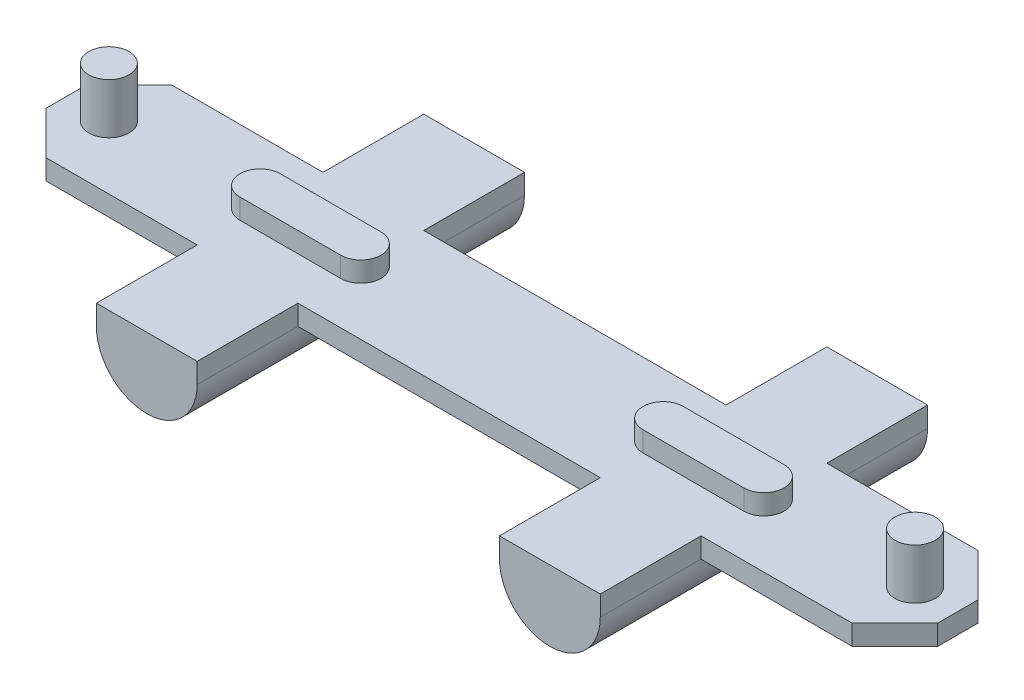
from build123d import *

# Parameters (mm, degrees)
SALIENTE_EXTRUIR1_DEPTH = 2
SALIENTE_EXTRUIR3_DEPTH = 2
CROQUIS3_R              = 2
SALIENTE_EXTRUIR4_DEPTH = 5
SALIENTE_EXTRUIR5_DEPTH = 32.48


with BuildPart() as part:
    # Croquis1 → Saliente-Extruir1 (new body)
    with BuildSketch(Plane(origin=(0, 0, 0), x_dir=(1, 0, 0), z_dir=(0, 1, 0))):
        Polygon((0, 0), (0, 4), (4.242640687, 8.242640687), (19.242640687, 8.242640687), (19.242640687, 18.242640687), (29.242640687, 18.242640687), (29.242640687, 8.242640687), (59.242640687, 8.242640687), (59.242640687, 18.242640687), (69.242640687, 18.242640687), (69.242640687, 8.242640687), (84.242640687, 8.242640687), (88.485281374, 4), (88.485281374, 0), (84.242640687, -4.242640687), (69.242640687, -4.242640687), (69.242640687, -14.242640687), (59.242640687, -14.242640687), (59.242640687, -4.242640687), (29.242640687, -4.242640687), (29.242640687, -14.242640687), (19.242640687, -14.242640687), (19.242640687, -4.242640687), (4.242640687, -4.242640687), align=None)
    extrude(amount=SALIENTE_EXTRUIR1_DEPTH)

    # Croquis2 → Saliente-Extruir3 (add)
    with BuildSketch(Plane(origin=(0, 2, 0), x_dir=(1, 0, 0), z_dir=(0, 1, 0))):
        with BuildLine():
            ThreePointArc((59.242640745, 0), (57.242640745, 2), (59.242640745, 4))
            Line((59.242640745, 4), (69.242640687, 4))
            ThreePointArc((69.242640687, 4), (71.242640687, 2), (69.242640687, 0))
            Line((69.242640687, 0), (59.242640745, 0))
        make_face()
        with BuildLine():
            Line((19.242640687, 0), (29.242640687, 0))
            ThreePointArc((29.242640687, 0), (31.242640629, 2), (29.242640687, 4))
            Line((29.242640687, 4), (19.242640687, 4))
            ThreePointArc((19.242640687, 4), (17.242640687, 2), (19.242640687, 0))
        make_face()
    extrude(amount=SALIENTE_EXTRUIR3_DEPTH)

    # Croquis3 → Saliente-Extruir4 (add)
    with BuildSketch(Plane(origin=(0, 2, 0), x_dir=(1, 0, 0), z_dir=(0, 1, 0))):
        with Locations((84.242640687, 2)):
            Circle(CROQUIS3_R)
        with Locations((4.242640687, 2)):
            Circle(CROQUIS3_R)
    extrude(amount=SALIENTE_EXTRUIR4_DEPTH)

    # Croquis4 → Saliente-Extruir5 (add)
    with BuildSketch(Plane.XY.offset(14.242640687)):
        with BuildLine():
            Line((19.242640687, 0), (29.242640687, 0))
            ThreePointArc((29.242640687, 0), (24.242640687, -5), (19.242640687, 0))
        make_face()
        with BuildLine():
            Line((59.242640687, 0), (69.242640687, 0))
            ThreePointArc((69.242640687, 0), (64.242640687, -5), (59.242640687, 0))
        make_face()
    extrude(amount=-SALIENTE_EXTRUIR5_DEPTH)


solid = part.part
